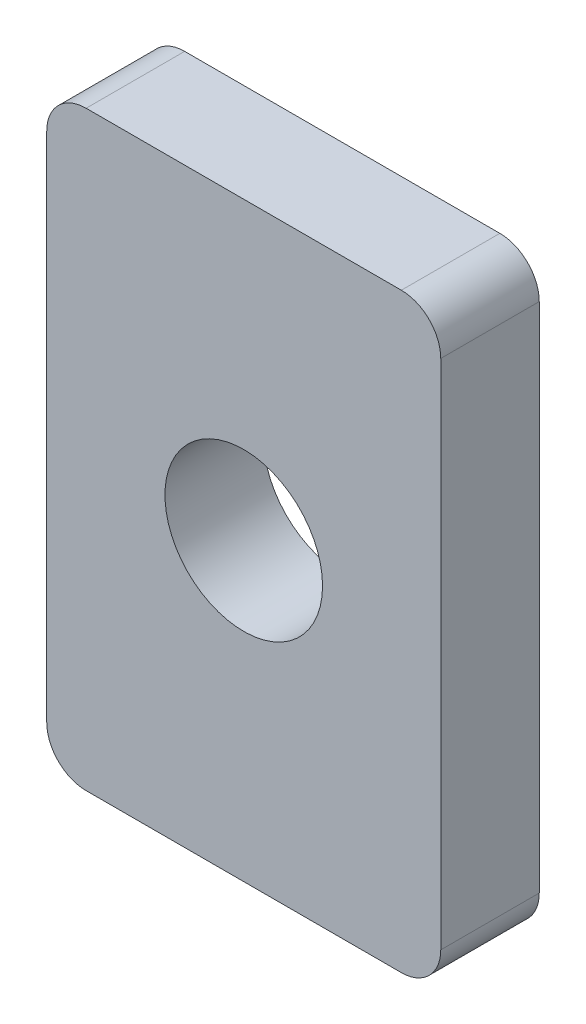
from build123d import *

# Parameters (mm, degrees)
SKETCH_1_W      = 10
SKETCH_1_H      = 15
SKETCH_1_R      = 2
EXTRUDE_1_DEPTH = 2.5
FILLET_1_R      = 1


with BuildPart() as part:
    # ｽｹｯﾁ1 → ﾎﾞｽ - 押し出し1 (new body)
    with BuildSketch(Plane.XY):
        Rectangle(SKETCH_1_W, SKETCH_1_H)
        Circle(SKETCH_1_R, mode=Mode.SUBTRACT)
    extrude(amount=EXTRUDE_1_DEPTH)

    # ﾌｨﾚｯﾄ1
    fillet_1_edges = [part.edges().sort_by_distance(p)[0] for p in [
        (5, -7.5, 1.25),
        (-5, -7.5, 1.25),
        (-5, 7.5, 1.25),
        (5, 7.5, 1.25),
    ]]
    fillet(fillet_1_edges, radius=FILLET_1_R)


solid = part.part
